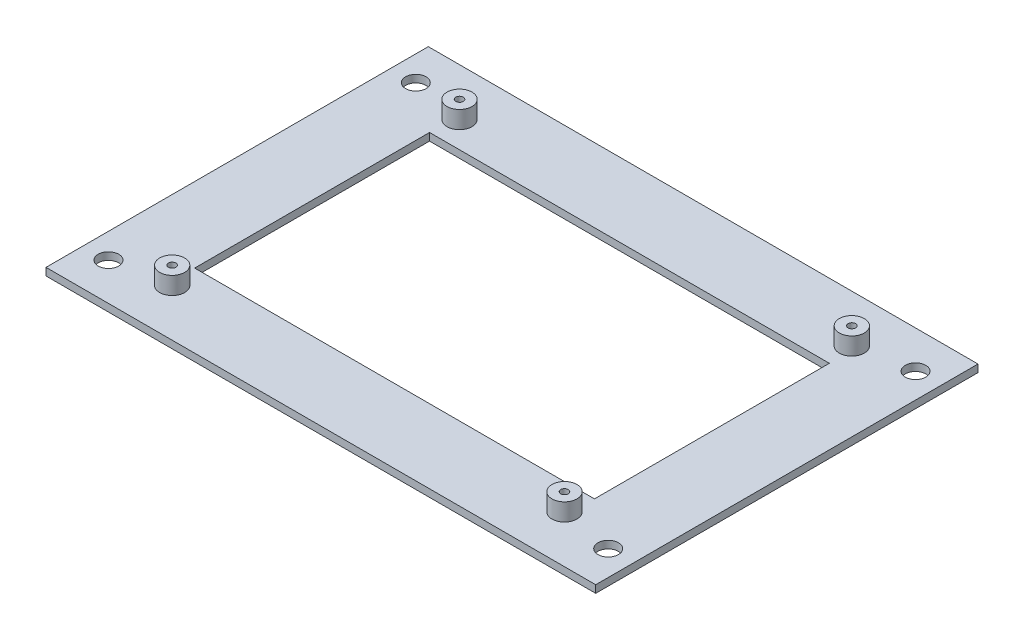
from build123d import *

# Parameters (mm, degrees)
CROQUIS1_W                = 220
CROQUIS1_H                = 153
SALIENTE_EXTRUIR1_DEPTH   = 3
CROQUIS2_W                = 160
CROQUIS2_H                = 94
CORTAR_EXTRUIR1_DEPTH     = 4
CROQUIS3_R                = 4.1
CORTAR_EXTRUIR2_DEPTH     = 4
CROQUIS4_R                = 5
SALIENTE_EXTRUIR2_DEPTH   = 7
CROQUIS5_R                = 1.5
CORTAR_EXTRUIR3_DEPTH     = 11
CORTAR_EXTRUIR4_DEPTH     = 3
SIMETR_A2_COPY_1_SKETCH_R = 4.1
SIMETR_A2_COPY_1_DEPTH    = 4
SIMETR_A2_COPY_2_SKETCH_R = 5
SIMETR_A2_COPY_2_DEPTH    = 7
SIMETR_A2_COPY_3_SKETCH_R = 1.5
SIMETR_A2_COPY_3_DEPTH    = 11
SIMETR_A2_COPY_4_DEPTH    = 3
SIMETR_A2_COPY_5_SKETCH_R = 5
SIMETR_A2_COPY_5_DEPTH    = 7
SIMETR_A2_COPY_6_SKETCH_R = 1.5
SIMETR_A2_COPY_6_DEPTH    = 11
SIMETR_A2_COPY_7_DEPTH    = 3


with BuildPart() as part:
    # Croquis1 → Saliente-Extruir1 (new body)
    with BuildSketch(Plane(origin=(0, 0, 0), x_dir=(1, 0, 0), z_dir=(0, 1, 0))):
        Rectangle(CROQUIS1_W, CROQUIS1_H)
    extrude(amount=SALIENTE_EXTRUIR1_DEPTH)

    # Croquis2 → Cortar-Extruir1 (cut, through all)
    with BuildSketch(Plane(origin=(0, 3, 0), x_dir=(1, 0, 0), z_dir=(0, 1, 0))):
        Rectangle(CROQUIS2_W, CROQUIS2_H)
    cortar_extruir1 = extrude(amount=-CORTAR_EXTRUIR1_DEPTH, mode=Mode.SUBTRACT)

    # Croquis3 → Cortar-Extruir2 (cut, through all)
    with BuildSketch(Plane(origin=(0, 3, 0), x_dir=(1, 0, 0), z_dir=(0, 1, 0))):
        with Locations((-100, 61.5)):
            Circle(CROQUIS3_R)
    cortar_extruir2 = extrude(amount=-CORTAR_EXTRUIR2_DEPTH, mode=Mode.SUBTRACT)

    # Croquis4 → Saliente-Extruir2 (add)
    with BuildSketch(Plane(origin=(0, 3, 0), x_dir=(1, 0, 0), z_dir=(0, 1, 0))):
        with Locations((-78.5, 57.5)):
            Circle(CROQUIS4_R)
    saliente_extruir2 = extrude(amount=SALIENTE_EXTRUIR2_DEPTH)

    # Croquis5 → Cortar-Extruir3 (cut, through all)
    with BuildSketch(Plane(origin=(0, 10, 0), x_dir=(1, 0, 0), z_dir=(0, 1, 0))):
        with Locations((-78.5, 57.5)):
            Circle(CROQUIS5_R)
    cortar_extruir3 = extrude(amount=-CORTAR_EXTRUIR3_DEPTH, mode=Mode.SUBTRACT)

    # Croquis6 → Cortar-Extruir4 (cut)
    with BuildSketch(Plane.XZ):
        Polygon((-81.675426481, -57.5), (-80.08771324, -60.25), (-76.91228676, -60.25), (-75.324573519, -57.5), (-76.91228676, -54.75), (-80.08771324, -54.75), align=None)
    cortar_extruir4 = extrude(amount=-CORTAR_EXTRUIR4_DEPTH, mode=Mode.SUBTRACT)

    # Simetría1: Cortar-Extruir2, Saliente-Extruir2, Cortar-Extruir3, Cortar-Extruir4 across plane
    add(cortar_extruir2.mirror(Plane(origin=(0, 0, 0), x_dir=(0, 0, 1), z_dir=(1, 0, 0))), mode=Mode.SUBTRACT)
    add(saliente_extruir2.mirror(Plane(origin=(0, 0, 0), x_dir=(0, 0, 1), z_dir=(1, 0, 0))))
    add(cortar_extruir3.mirror(Plane(origin=(0, 0, 0), x_dir=(0, 0, 1), z_dir=(1, 0, 0))), mode=Mode.SUBTRACT)
    add(cortar_extruir4.mirror(Plane(origin=(0, 0, 0), x_dir=(0, 0, 1), z_dir=(1, 0, 0))), mode=Mode.SUBTRACT)

    # Simetría2: Cortar-Extruir1, Cortar-Extruir2 across plane
    add(cortar_extruir1.mirror(Plane.XY), mode=Mode.SUBTRACT)
    add(cortar_extruir2.mirror(Plane.XY), mode=Mode.SUBTRACT)

    # Simetría2 copy 1 sketch → Simetría2 copy 1 (cut, through all)
    with BuildSketch(Plane(origin=(0, 3, 0), x_dir=(-1, 0, 0), z_dir=(0, 1, 0))):
        with Locations((-100, 61.5)):
            Circle(SIMETR_A2_COPY_1_SKETCH_R)
    extrude(amount=-SIMETR_A2_COPY_1_DEPTH, mode=Mode.SUBTRACT)

    # Simetría2 copy 2 sketch → Simetría2 copy 2 (add)
    with BuildSketch(Plane(origin=(0, 3, 0), x_dir=(-1, 0, 0), z_dir=(0, 1, 0))):
        with Locations((-78.5, 57.5)):
            Circle(SIMETR_A2_COPY_2_SKETCH_R)
    extrude(amount=SIMETR_A2_COPY_2_DEPTH)

    # Simetría2 copy 3 sketch → Simetría2 copy 3 (cut, through all)
    with BuildSketch(Plane(origin=(0, 10, 0), x_dir=(-1, 0, 0), z_dir=(0, 1, 0))):
        with Locations((-78.5, 57.5)):
            Circle(SIMETR_A2_COPY_3_SKETCH_R)
    extrude(amount=-SIMETR_A2_COPY_3_DEPTH, mode=Mode.SUBTRACT)

    # Simetría2 copy 4 sketch → Simetría2 copy 4 (cut)
    with BuildSketch(Plane(origin=(0, 0, 0), x_dir=(-1, 0, 0), z_dir=(0, -1, 0))):
        Polygon((-81.675426481, -57.5), (-80.08771324, -60.25), (-76.91228676, -60.25), (-75.324573519, -57.5), (-76.91228676, -54.75), (-80.08771324, -54.75), align=None)
    extrude(amount=-SIMETR_A2_COPY_4_DEPTH, mode=Mode.SUBTRACT)

    # Simetría2 copy 5 sketch → Simetría2 copy 5 (add)
    with BuildSketch(Plane(origin=(0, 3, 0), x_dir=(1, 0, 0), z_dir=(0, 1, 0))):
        with Locations((-78.5, -57.5)):
            Circle(SIMETR_A2_COPY_5_SKETCH_R)
    extrude(amount=SIMETR_A2_COPY_5_DEPTH)

    # Simetría2 copy 6 sketch → Simetría2 copy 6 (cut, through all)
    with BuildSketch(Plane(origin=(0, 10, 0), x_dir=(1, 0, 0), z_dir=(0, 1, 0))):
        with Locations((-78.5, -57.5)):
            Circle(SIMETR_A2_COPY_6_SKETCH_R)
    extrude(amount=-SIMETR_A2_COPY_6_DEPTH, mode=Mode.SUBTRACT)

    # Simetría2 copy 7 sketch → Simetría2 copy 7 (cut)
    with BuildSketch(Plane.XZ):
        Polygon((-81.675426481, 57.5), (-80.08771324, 60.25), (-76.91228676, 60.25), (-75.324573519, 57.5), (-76.91228676, 54.75), (-80.08771324, 54.75), align=None)
    extrude(amount=-SIMETR_A2_COPY_7_DEPTH, mode=Mode.SUBTRACT)


solid = part.part
